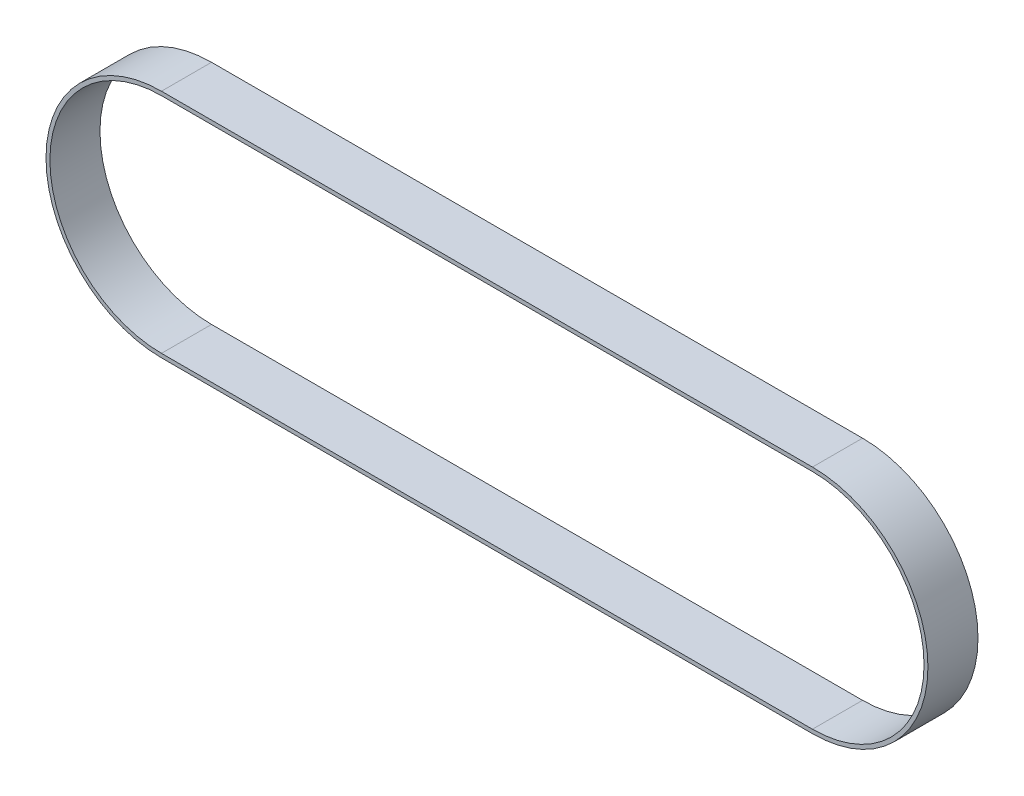
from build123d import *

# Parameters (mm, degrees)
BOSS_EXTRUDE1_DEPTH = 15


with BuildPart() as part:
    # Sketch1 → Boss-Extrude1 (new body)
    with BuildSketch(Plane.XY):
        with BuildLine():
            Line((0, 34.5948), (195.0466, 34.5948))
            ThreePointArc((195.0466, 34.5948), (229.6414, 0), (195.0466, -34.5948))
            Line((195.0466, -34.5948), (0, -34.5948))
            ThreePointArc((0, -34.5948), (-34.5948, 0), (0, 34.5948))
        make_face()
        with BuildLine():
            Line((0, 33.4264), (195.0466, 33.4264))
            ThreePointArc((195.0466, 33.4264), (228.473, 0), (195.0466, -33.4264))
            Line((195.0466, -33.4264), (0, -33.4264))
            ThreePointArc((0, -33.4264), (-33.4264, 0), (0, 33.4264))
        make_face(mode=Mode.SUBTRACT)
    extrude(amount=BOSS_EXTRUDE1_DEPTH)


solid = part.part
